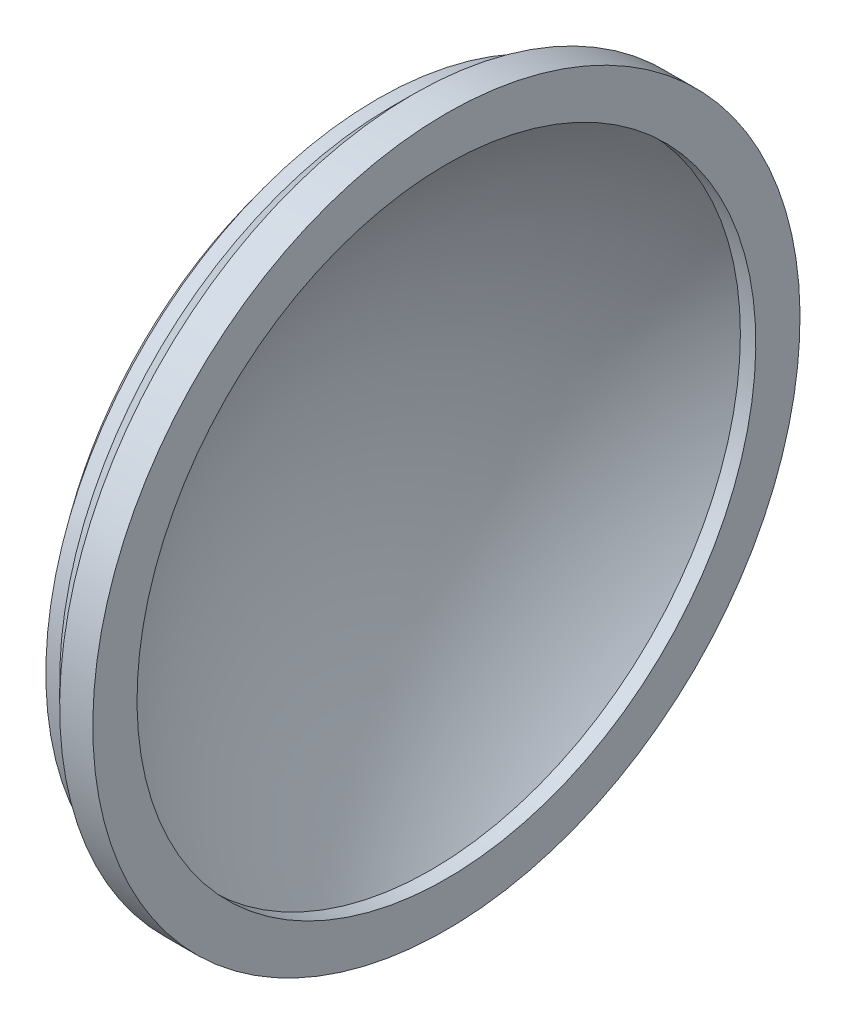
from build123d import *


with BuildPart() as part:
    # Sketch1 → Revolve1 (revolve)
    with BuildSketch(Plane.XY):
        with BuildLine():
            Line((-16, 64), (-16, 56))
            Line((-16, 56), (-18.790689802, 56))
            ThreePointArc((-18.790689802, 56), (-34.407796248, 29.913629212), (-39.845400687, 0))
            Line((-39.845400687, 0), (-49.845400687, 0))
            ThreePointArc((-49.845400687, 0), (-44.350112671, 31.841899011), (-28.5, 60))
            Line((-28.5, 60), (-26, 60))
            Line((-26, 60), (-22, 64))
            Line((-22, 64), (-16, 64))
        make_face()
    revolve(axis=Axis((0, 0, 0), (-1, 0, 0)))


solid = part.part
